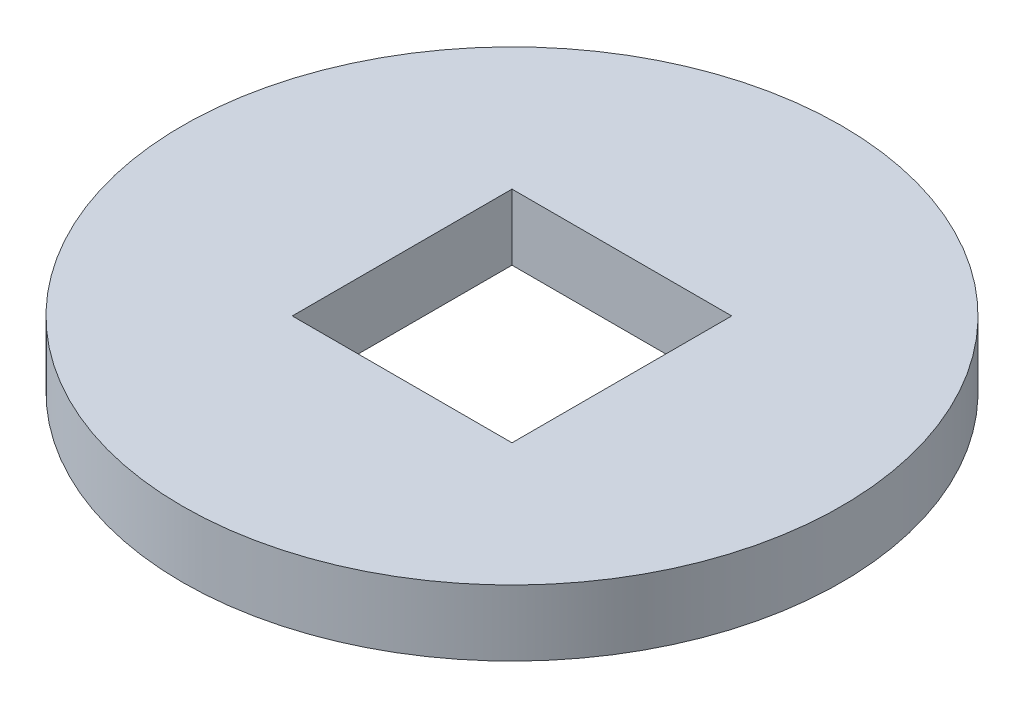
from build123d import *

# Parameters (mm, degrees)
SKETCH1_R           = 30
SKETCH1_W           = 20
SKETCH1_H           = 20
BOSS_EXTRUDE1_DEPTH = 6


with BuildPart() as part:
    # Sketch1 → Boss-Extrude1 (new body)
    with BuildSketch(Plane(origin=(0, 0, 0), x_dir=(1, 0, 0), z_dir=(0, 1, 0))):
        Circle(SKETCH1_R)
        Rectangle(SKETCH1_W, SKETCH1_H, mode=Mode.SUBTRACT)
    extrude(amount=BOSS_EXTRUDE1_DEPTH)


solid = part.part
